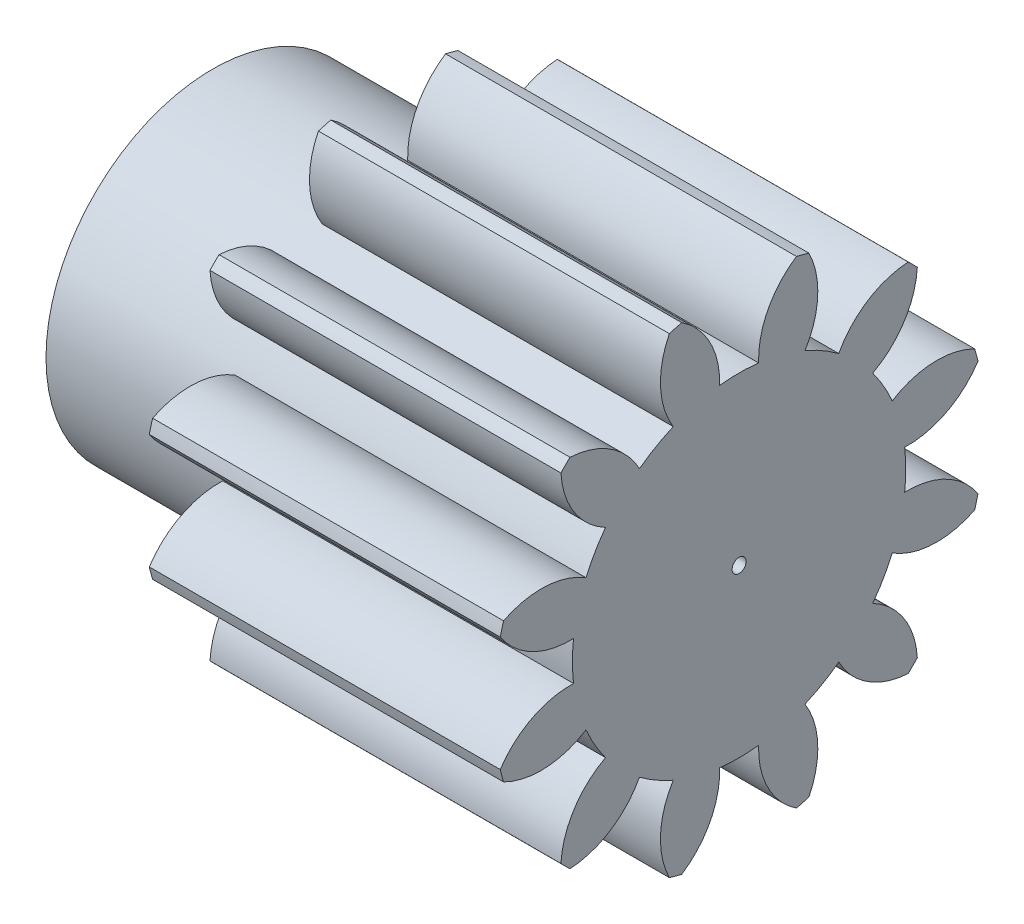
from build123d import *
from build123d.topology import SkipClean

# Parameters (mm, degrees)
BASPROSKE_W      = 20
BASPROSKE_H      = 14
TOOTHCUT_DEPTH   = 29.142494559
TEETHCUTS_COUNT  = 12
TEETHCUTS_ANGLE  = 330
HUBNEAONESKE_R   = 9.499
HUBNEARONE_DEPTH = 10.0000508
BORSKE_R         = 0.4
BORE_DEPTH       = 30.0000508


with BuildPart() as part:
    # BasProSke → Base-Revolve (revolve)
    with BuildSketch(Plane(origin=(0, 0, 0), x_dir=(1, 0, 0), z_dir=(0, 1, 0)), mode=Mode.PRIVATE) as base_revolve_sk:
        with Locations((10, 7)):
            Rectangle(BASPROSKE_W, BASPROSKE_H)
    revolve(base_revolve_sk.sketch.rotate(Axis((-10, 0, 0), (1, 0, 0)), 180), axis=Axis((-10, 0, 0), (1, 0, 0)))

    # TooCutSke → ToothCut (cut, through all)
    with BuildSketch(Plane(origin=(0, 0, 0), x_dir=(0, 0, -1), z_dir=(1, 0, 0))):
        with BuildLine():
            ThreePointArc((1.111908866, 9.433698091), (0, 9.499), (-1.111908866, 9.433698091))
            ThreePointArc((-1.111908866, 9.433698091), (-1.651516138, 11.821129337), (-3.298149691, 13.632096456))
            ThreePointArc((-3.298149691, 13.632096456), (0, 14.0254), (3.298149691, 13.632096456))
            ThreePointArc((3.298149691, 13.632096456), (1.651516138, 11.821129337), (1.111908866, 9.433698091))
        make_face()
    toothcut = extrude(amount=TOOTHCUT_DEPTH, mode=Mode.SUBTRACT)

    # TeethCuts: ToothCut ×12 about axis
    teethcuts_axis = Axis((-10, 0, 0), (1, 0, 0))
    for i in range(1, TEETHCUTS_COUNT):
        add(toothcut.rotate(teethcuts_axis, i * TEETHCUTS_ANGLE / (TEETHCUTS_COUNT - 1)), mode=Mode.SUBTRACT)

    # HubNeaOneSke → HubNearOne (add)
    with SkipClean():  # the faces are left unmerged after this step: merging them gives an invalid solid
        with BuildSketch(Plane.ZY):
            Circle(HUBNEAONESKE_R)
        extrude(amount=HUBNEARONE_DEPTH)

    # BorSke → Bore (cut, symmetric)
    with SkipClean():  # the faces are left unmerged after this step: merging them gives an invalid solid
        with BuildSketch(Plane(origin=(0, 0, 0), x_dir=(0, 0, -1), z_dir=(1, 0, 0))):
            with Locations(Location((0, 0, 0), (0, 0, 180))):
                Circle(BORSKE_R)
        extrude(amount=BORE_DEPTH, both=True, mode=Mode.SUBTRACT)


solid = part.part
